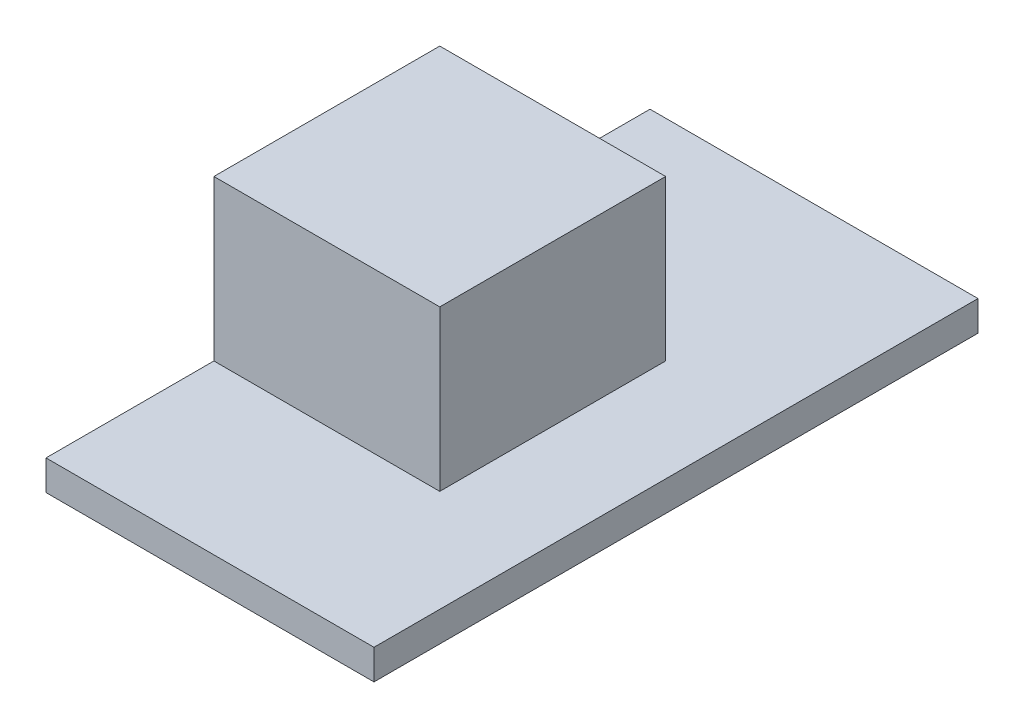
from build123d import *

# Parameters (mm, degrees)
SKETCH1_W           = 10.92
SKETCH1_H           = 20.11
BOSS_EXTRUDE1_DEPTH = 1
SKETCH2_W           = 7.52
SKETCH2_H           = 7.52
BOSS_EXTRUDE2_DEPTH = 5.32


with BuildPart() as part:
    # Sketch1 → Boss-Extrude1 (new body)
    with BuildSketch(Plane(origin=(0, 0, 0), x_dir=(1, 0, 0), z_dir=(0, 1, 0))):
        Rectangle(SKETCH1_W, SKETCH1_H)
    extrude(amount=BOSS_EXTRUDE1_DEPTH)

    # Sketch2 → Boss-Extrude2 (add)
    with BuildSketch(Plane(origin=(0, 1, 0), x_dir=(1, 0, 0), z_dir=(0, 1, 0))):
        with Locations((-1.7, -0.705)):
            Rectangle(SKETCH2_W, SKETCH2_H)
    extrude(amount=BOSS_EXTRUDE2_DEPTH)


solid = part.part
